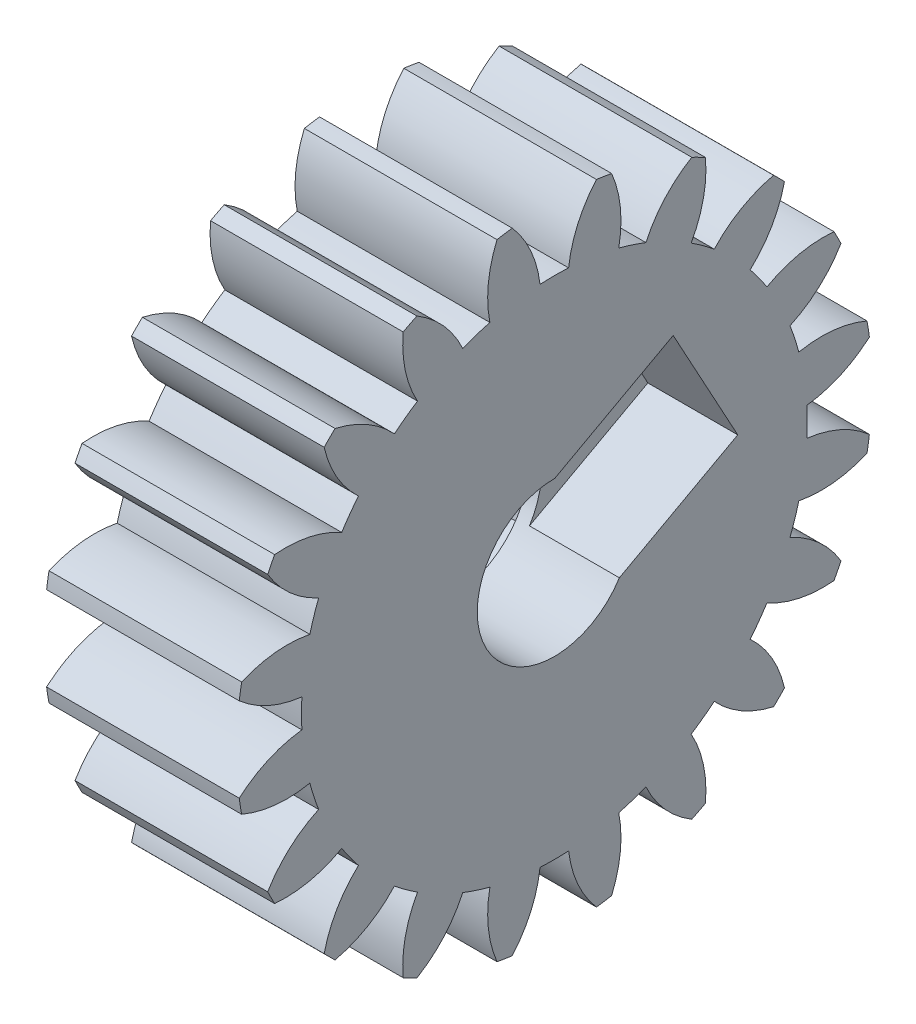
from build123d import *

# Parameters (mm, degrees)
BASPROSKE_W        = 15
BASPROSKE_H        = 24.75
TOOTHCUT_DEPTH     = 39.080506824
TEETHCUTS_COUNT    = 20
BORSKE_R           = 6
BORE_DEPTH         = 50.0000508
SKETCH1_R          = 6
CUT_EXTRUDE1_DEPTH = 7
CUT_EXTRUDE2_DEPTH = 7


with BuildPart() as part:
    # BasProSke → Base-Revolve (revolve)
    with BuildSketch(Plane(origin=(0, 0, 0), x_dir=(1, 0, 0), z_dir=(0, 1, 0)), mode=Mode.PRIVATE) as base_revolve_sk:
        with Locations((7.5, 12.375)):
            Rectangle(BASPROSKE_W, BASPROSKE_H)
    revolve(base_revolve_sk.sketch.rotate(Axis((-10, 0, 0), (1, 0, 0)), 180), axis=Axis((-10, 0, 0), (1, 0, 0)))

    # TooCutSke → ToothCut (cut, through all)
    with BuildSketch(Plane(origin=(0, 0, 0), x_dir=(0, 0, -1), z_dir=(1, 0, 0))):
        with BuildLine():
            ThreePointArc((1.111948432, 19.655071939), (0, 19.6865), (-1.111948432, 19.655071939))
            ThreePointArc((-1.111948432, 19.655071939), (-1.832349961, 22.271720111), (-3.300041734, 24.55463642))
            ThreePointArc((-3.300041734, 24.55463642), (0, 24.7754), (3.300041734, 24.55463642))
            ThreePointArc((3.300041734, 24.55463642), (1.832349961, 22.271720111), (1.111948432, 19.655071939))
        make_face()
    toothcut = extrude(amount=TOOTHCUT_DEPTH, mode=Mode.SUBTRACT)

    # TeethCuts: ToothCut ×20 about axis
    teethcuts_axis = Axis((0, 0, 0), (1, 0, 0))
    for i in range(1, TEETHCUTS_COUNT):
        add(toothcut.rotate(teethcuts_axis, i * 360 / TEETHCUTS_COUNT), mode=Mode.SUBTRACT)

    # BorSke → Bore (cut, symmetric)
    with BuildSketch(Plane(origin=(0, 0, 0), x_dir=(0, 0, -1), z_dir=(1, 0, 0))):
        with Locations(Location((0, 0, 0), (0, 0, 180))):
            Circle(BORSKE_R)
    extrude(amount=BORE_DEPTH, both=True, mode=Mode.SUBTRACT)

    # Sketch1 → Cut-Extrude1 (cut)
    with BuildSketch(Plane(origin=(15, 0, 0), x_dir=(0, 0, -1), z_dir=(1, 0, 0))):
        with BuildLine():
            ThreePointArc((6, 0), (4.255305349, 4.229938107), (0.035874537, 5.999892751))
            Line((0.035874537, 5.999892751), (5.064141431, -3.217836473))
            ThreePointArc((5.064141431, -3.217836473), (5.761286687, -1.675582199), (6, 0))
        make_face()
        with BuildLine():
            Line((5.064141431, -3.217836473), (0.035874537, 5.999892751))
            ThreePointArc((0.035874537, 5.999892751), (-5.267273842, -2.873295368), (5.064141431, -3.217836473))
        make_face()
        with Locations(Location((0, 0, 0), (0, 0, 89.657421369))):
            Circle(SKETCH1_R)
        Polygon((0.035874537, 5.999892751), (5.064141431, -3.217836473), (14.281870655, 1.810430421), (9.25360376, 11.028159645), align=None)
    extrude(amount=-CUT_EXTRUDE1_DEPTH, mode=Mode.SUBTRACT)

    # Sketch2 → Cut-Extrude2 (cut)
    with BuildSketch(Plane.ZY):
        Polygon((13.03803352, -4.691447745), (10.581929687, 8.945544371), (-2.456103832, 13.636992116), (-13.03803352, 4.691447745), (-10.581929687, -8.945544371), (2.456103832, -13.636992116), align=None)
        Polygon((13.636992116, 2.456103832), (4.691447745, 13.03803352), (-8.945544371, 10.581929687), (-13.636992116, -2.456103832), (-4.691447745, -13.03803352), (8.945544371, -10.581929687), align=None)
        Polygon((-13.636992116, -2.456103832), (-11.240040726, -5.291523347), (-12.379922481, 1.03742672), align=None)
        Polygon((-10.581929687, -8.945544371), (-7.088399135, -10.202614006), (-11.240040726, -5.291523347), align=None)
        Polygon((-4.691447745, -13.03803352), (-1.03742672, -12.379922481), (-7.088399135, -10.202614006), align=None)
        Polygon((2.456103832, -13.636992116), (5.291523347, -11.240040726), (-1.03742672, -12.379922481), align=None)
        Polygon((8.945544371, -10.581929687), (10.202614006, -7.088399135), (5.291523347, -11.240040726), align=None)
        Polygon((10.202614006, -7.088399135), (13.03803352, -4.691447745), (12.379922481, -1.03742672), align=None)
        Polygon((7.088399135, 10.202614006), (11.240040726, 5.291523347), (10.581929687, 8.945544371), align=None)
        Polygon((11.240040726, 5.291523347), (12.379922481, -1.03742672), (13.636992116, 2.456103832), align=None)
        Polygon((1.03742672, 12.379922481), (7.088399135, 10.202614006), (4.691447745, 13.03803352), align=None)
        Polygon((-5.291523347, 11.240040726), (1.03742672, 12.379922481), (-2.456103832, 13.636992116), align=None)
        Polygon((-10.202614006, 7.088399135), (-5.291523347, 11.240040726), (-8.945544371, 10.581929687), align=None)
        Polygon((-12.379922481, 1.03742672), (-10.202614006, 7.088399135), (-13.03803352, 4.691447745), align=None)
    extrude(amount=-CUT_EXTRUDE2_DEPTH, mode=Mode.SUBTRACT)


solid = part.part
